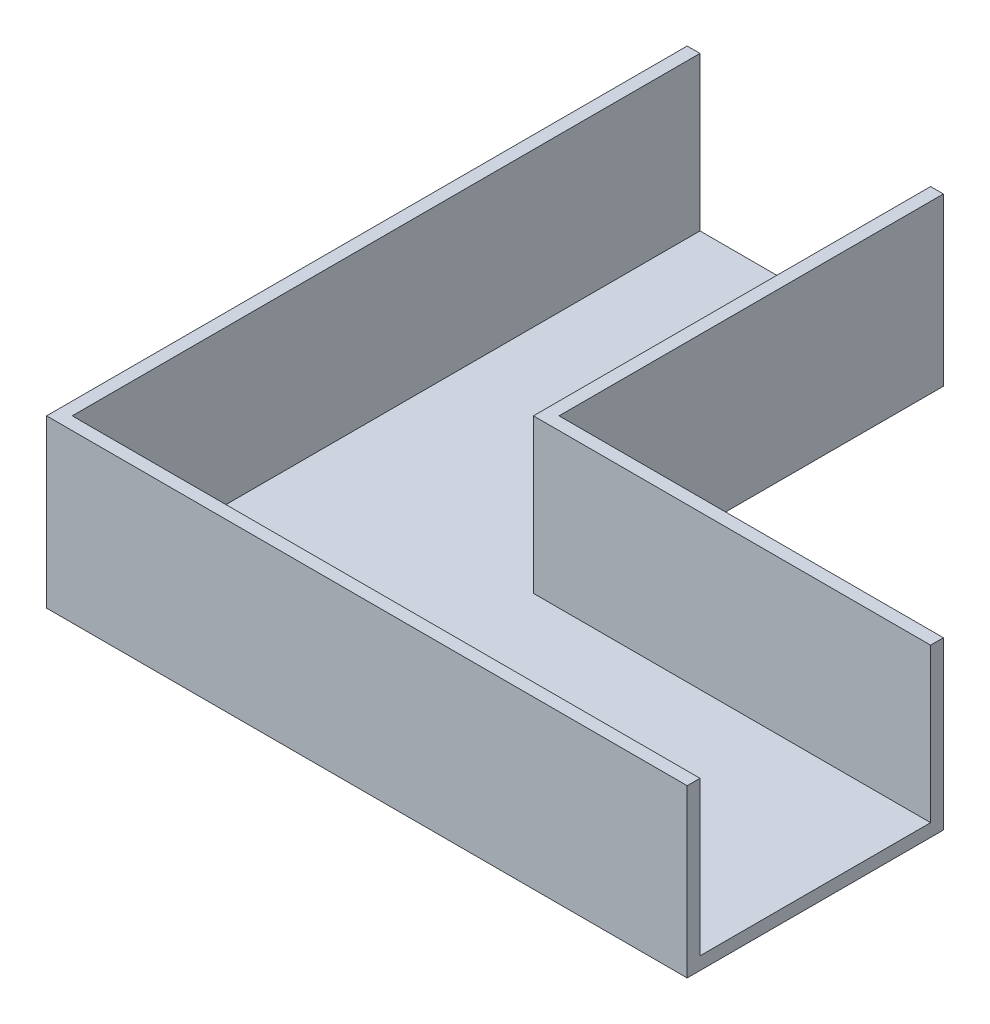
from build123d import *

# Parameters (mm, degrees)
BOSS_EXTRUDE1_DEPTH = 330.2
CUT_EXTRUDE2_DEPTH  = 304.8


with BuildPart() as part:
    # Sketch1 → Boss-Extrude1 (new body)
    with BuildSketch(Plane(origin=(0, 0, 0), x_dir=(1, 0, 0), z_dir=(0, 1, 0))):
        Polygon((0, 0), (1270, 0), (1270, 508), (508, 508), (508, 1270), (0, 1270), align=None)
    extrude(amount=BOSS_EXTRUDE1_DEPTH)

    # Sketch2 → Cut-Extrude2 (cut)
    with BuildSketch(Plane(origin=(0, 330.2, 0), x_dir=(1, 0, 0), z_dir=(0, 1, 0))):
        Polygon((25.4, 1270), (25.4, 25.4), (1270, 25.4), (1270, 482.6), (482.6, 482.6), (482.6, 1270), align=None)
    extrude(amount=-CUT_EXTRUDE2_DEPTH, mode=Mode.SUBTRACT)


solid = part.part
